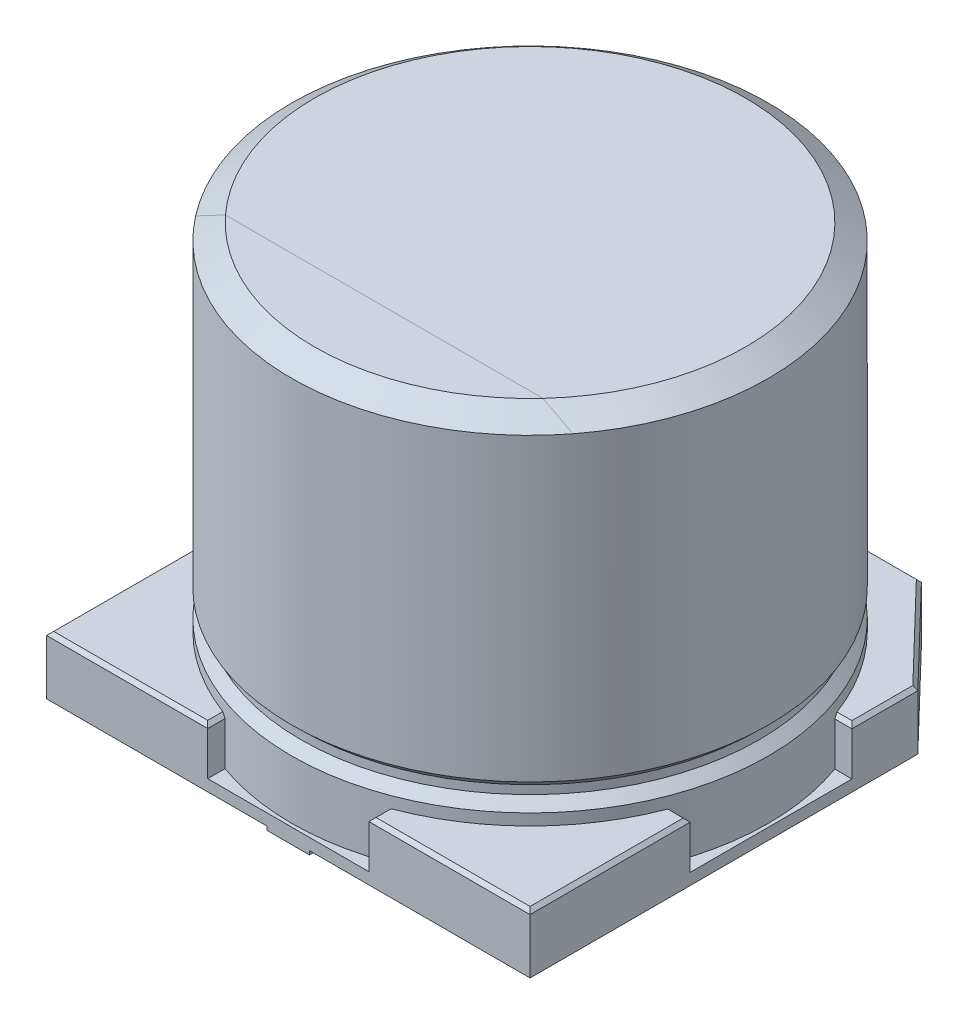
from build123d import *

# Parameters (mm, degrees)
BOSS_EXTRUDE1_DEPTH = 0.1571
BOSS_EXTRUDE2_DEPTH = 0.6443
CHAMFER1_SIZE       = 0.0487
BOSS_EXTRUDE3_START = -0.1571
BOSS_EXTRUDE3_DEPTH = 0.0514
SKETCH2_R           = 3.27
BOSS_EXTRUDE4_DEPTH = 5.5
CHAMFER2_SIZE       = 0.2155
CHAMFER2_SIZE2      = 0.314


with BuildPart() as part:
    # Sketch1 → Boss-Extrude1 (new body)
    with BuildSketch(Plane(origin=(0, 0, 0), x_dir=(1, 0, 0), z_dir=(0, 1, 0))):
        Polygon((-1.115015984, 1.105000019), (-1.120023966, 3.314999898), (-2.051918983, 3.314999898), (-3.314999898, 2.002368291), (-3.314999898, 1.098344008), align=None)
        Polygon((0, -1.592377345), (0, 1.592377345), (-0.288244069, 1.592377345), (-0.28754435, 3.314999898), (-1.120023966, 3.314999898), (-1.115015984, 1.105000019), (-3.314999898, 1.098344008), (-3.314999898, -1.118712743), (-1.110008001, -1.105000019), (-1.105000019, -3.314999898), (-0.289643526, -3.314999898), (-0.288943807, -1.592377345), align=None)
        Polygon((-3.314999898, -3.314999898), (-1.105000019, -3.314999898), (-1.110008001, -1.105000019), (-3.314999898, -1.118712743), align=None)
        Polygon((0.288943807, -1.592377345), (0, -1.592377345), (0, -3.314999898), (0.289643526, -3.314999898), align=None)
        Polygon((0, -3.314999898), (0, -1.592377345), (-0.288943807, -1.592377345), (-0.289643526, -3.314999898), align=None)
        Polygon((0, 1.592377345), (0, 3.314999898), (-0.28754435, 3.314999898), (-0.288244069, 1.592377345), align=None)
        Polygon((0.28754435, 3.314999898), (0, 3.314999898), (0, 1.592377345), (0.288244069, 1.592377345), align=None)
        Polygon((0.288244069, 1.592377345), (0, 1.592377345), (0, -1.592377345), (0.288943807, -1.592377345), (0.289643526, -3.314999898), (1.105000019, -3.314999898), (1.110008001, -1.10500002), (3.314999898, -1.118712743), (3.314999898, 1.098344008), (1.115015984, 1.105000019), (1.120023966, 3.314999898), (0.28754435, 3.314999898), align=None)
        Polygon((2.051671346, 3.314999898), (1.120023966, 3.314999898), (1.115015984, 1.105000019), (3.314999898, 1.098344008), (3.314999898, 2.002368291), align=None)
        Polygon((1.110008001, -1.10500002), (1.105000019, -3.314999898), (3.314999898, -3.314999898), (3.314999898, -1.118712743), align=None)
    extrude(amount=-BOSS_EXTRUDE1_DEPTH)

    # Sketch1_4 → Boss-Extrude2 (add)
    with BuildSketch(Plane(origin=(0, 0, 0), x_dir=(1, 0, 0), z_dir=(0, 1, 0))):
        Polygon((-1.115015984, 1.105000019), (-1.120023966, 3.314999898), (-2.051918983, 3.314999898), (-3.314999898, 2.002368291), (-3.314999898, 1.098344008), align=None)
        Polygon((-3.314999898, -3.314999898), (-1.105000019, -3.314999898), (-1.110008001, -1.105000019), (-3.314999898, -1.118712743), align=None)
        Polygon((1.115015984, 1.105000019), (3.314999898, 1.098344008), (3.314999898, 2.002368291), (2.051671346, 3.314999898), (1.120023966, 3.314999898), align=None)
        Polygon((1.105000019, -3.314999898), (3.314999898, -3.314999898), (3.314999898, -1.118712743), (1.110008001, -1.10500002), align=None)
    extrude(amount=BOSS_EXTRUDE2_DEPTH)

    # Chamfer1
    chamfer1_edges = [part.edges().sort_by_distance(p)[0] for p in [
        (2.212503949, 0.6443, 1.111856381),
        (3.314999898, 0.6443, 2.216856321),
        (2.209999959, 0.6443, 3.314999898),
        (1.10750401, 0.6443, 2.209999959),
        (1.117519975, 0.6443, -2.209999959),
        (1.585847656, 0.6443, -3.314999898),
        (2.683335622, 0.6443, -2.658684095),
        (3.314999898, 0.6443, -1.55035615),
        (2.215007941, 0.6443, -1.101672014),
        (-2.215007941, 0.6443, -1.101672014),
        (-3.314999898, 0.6443, -1.55035615),
        (-2.683459441, 0.6443, -2.658684095),
        (-1.585971475, 0.6443, -3.314999898),
        (-1.117519975, 0.6443, -2.209999959),
        (-2.209999959, 0.6443, 3.314999898),
        (-3.314999898, 0.6443, 2.216856321),
        (-2.21250395, 0.6443, 1.111856381),
        (-1.10750401, 0.6443, 2.209999959),
    ]]
    chamfer(chamfer1_edges, length=CHAMFER1_SIZE)

    # Sketch1_5 → Boss-Extrude3 (add)
    with BuildSketch(Plane(origin=(0, 0, 0), x_dir=(1, 0, 0), z_dir=(0, 1, 0)).offset(BOSS_EXTRUDE3_START)):
        Polygon((0, -3.314999898), (0, -1.592377345), (-0.288943807, -1.592377345), (-0.289643526, -3.314999898), align=None)
        Polygon((0.288943807, -1.592377345), (0, -1.592377345), (0, -3.314999898), (0.289643526, -3.314999898), align=None)
        Polygon((0, 1.592377345), (0, 3.314999898), (-0.28754435, 3.314999898), (-0.288244069, 1.592377345), align=None)
        Polygon((0.28754435, 3.314999898), (0, 3.314999898), (0, 1.592377345), (0.288244069, 1.592377345), align=None)
    extrude(amount=-BOSS_EXTRUDE3_DEPTH)

    # Sketch2 → Boss-Extrude4 (add)
    with BuildSketch(Plane(origin=(0, 0, 0), x_dir=(1, 0, 0), z_dir=(0, 1, 0))):
        with Locations(Location((0, 0, 0), (0, 0, 69.980077841))):
            Circle(SKETCH2_R)
    extrude(amount=BOSS_EXTRUDE4_DEPTH)

    # Chamfer2
    chamfer2_edges = [part.edges().sort_by_distance(p)[0] for p in [
        (-1.119474234, 5.5, 3.072405806),
    ]]
    chamfer2_side = [part.faces().sort_by_distance(p)[0] for p in [
        (-1.119474234, 2.75, 3.072405806),
    ]]
    chamfer(chamfer2_edges, length=CHAMFER2_SIZE, length2=CHAMFER2_SIZE2, reference=chamfer2_side[0])

    # Sketch3 → Cut-Revolve1 (revolve, cut)
    with BuildSketch(Plane.XY, mode=Mode.PRIVATE) as cut_revolve1_sk:
        Polygon((3.1392, 1.0429), (3.1392, 0.9251), (3.27, 0.8), (3.27, 1.168), align=None)
    revolve(cut_revolve1_sk.sketch.rotate(Axis((0, 5.2845, 0), (0, -1, 0)), 290.019922159), axis=Axis((0, 5.2845, 0), (0, -1, 0)), mode=Mode.SUBTRACT)


solid = part.part
